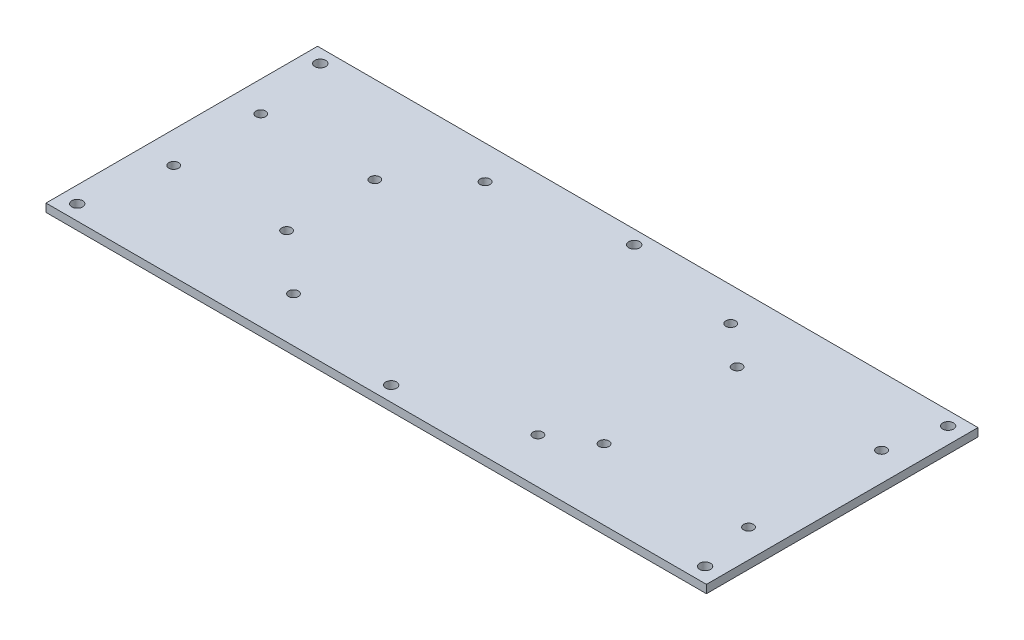
from build123d import *

# Parameters (mm, degrees)
SKETCH_181_W    = 243.2
SKETCH_181_H    = 100
SKETCH_181_R    = 1.8
SKETCH_181_R_2  = 2
EXTRUDE_3_DEPTH = 3


with BuildPart() as part:
    # Sketch 181 → 凸台-拉伸3 (new body)
    with BuildSketch(Plane(origin=(0, 0, 0), x_dir=(1, 0, 0), z_dir=(0, 1, 0))):
        with Locations((120.6, -50)):
            Rectangle(SKETCH_181_W, SKETCH_181_H)
        with Locations(Location((73.049576153, -12.361926171, 0), (0, 0, 270))):  # turned: the seam where the file's is
            Circle(SKETCH_181_R, mode=Mode.SUBTRACT)
        with Locations(Location((73.495550598, -83.360525501, 0), (0, 0, 270))):  # turned: the seam where the file's is
            Circle(SKETCH_181_R, mode=Mode.SUBTRACT)
        with Locations(Location((163.495550598, -12.360525501, 0), (0, 0, 270))):  # turned: the seam where the file's is
            Circle(SKETCH_181_R, mode=Mode.SUBTRACT)
        with Locations(Location((163.495550598, -83.360525501, 0), (0, 0, 270))):  # turned: the seam where the file's is
            Circle(SKETCH_181_R, mode=Mode.SUBTRACT)
        with Locations(Location((10.091186927, -32, 0), (0, 0, 270))):  # turned: the seam where the file's is
            Circle(SKETCH_181_R, mode=Mode.SUBTRACT)
        with Locations(Location((10.522883477, -64.497132767, 0), (0, 0, 270))):  # turned: the seam where the file's is
            Circle(SKETCH_181_R, mode=Mode.SUBTRACT)
        with Locations(Location((52.091186927, -32, 0), (0, 0, 270))):  # turned: the seam where the file's is
            Circle(SKETCH_181_R, mode=Mode.SUBTRACT)
        with Locations(Location((52.091186927, -64.497132767, 0), (0, 0, 270))):  # turned: the seam where the file's is
            Circle(SKETCH_181_R, mode=Mode.SUBTRACT)
        with Locations(Location((120.6, -5, 0), (0, 0, 270))):  # turned: the seam where the file's is
            Circle(SKETCH_181_R_2, mode=Mode.SUBTRACT)
        with Locations(Location((120.6, -94.5, 0), (0, 0, 270))):  # turned: the seam where the file's is
            Circle(SKETCH_181_R_2, mode=Mode.SUBTRACT)
        with Locations(Location((5, -5, 0), (0, 0, 270))):  # turned: the seam where the file's is
            Circle(SKETCH_181_R_2, mode=Mode.SUBTRACT)
        with Locations(Location((5, -94.5, 0), (0, 0, 270))):  # turned: the seam where the file's is
            Circle(SKETCH_181_R_2, mode=Mode.SUBTRACT)
        with Locations(Location((236.2, -5, 0), (0, 0, 270))):  # turned: the seam where the file's is
            Circle(SKETCH_181_R_2, mode=Mode.SUBTRACT)
        with Locations(Location((236.2, -94.5, 0), (0, 0, 270))):  # turned: the seam where the file's is
            Circle(SKETCH_181_R_2, mode=Mode.SUBTRACT)
        with Locations(Location((231.695550598, -25, 0), (0, 0, 270))):  # turned: the seam where the file's is
            Circle(SKETCH_181_R, mode=Mode.SUBTRACT)
        with Locations(Location((231.695550598, -74, 0), (0, 0, 270))):  # turned: the seam where the file's is
            Circle(SKETCH_181_R, mode=Mode.SUBTRACT)
        with Locations(Location((178.495550598, -74, 0), (0, 0, 270))):  # turned: the seam where the file's is
            Circle(SKETCH_181_R, mode=Mode.SUBTRACT)
        with Locations(Location((178.495550598, -25, 0), (0, 0, 270))):  # turned: the seam where the file's is
            Circle(SKETCH_181_R, mode=Mode.SUBTRACT)
    extrude(amount=EXTRUDE_3_DEPTH)


solid = part.part
